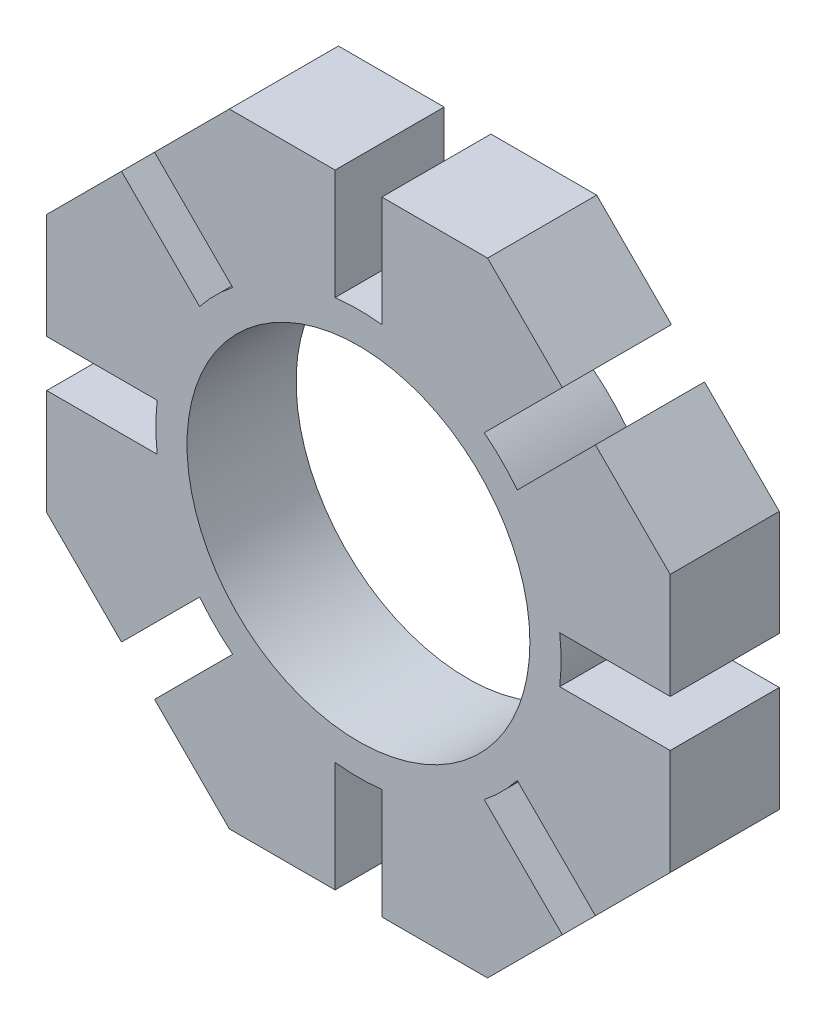
from build123d import *

# Parameters (mm, degrees)
SKETCH1_R               = 11
BOSS_EXTRUDE1_DEPTH     = 3.5
CUT_EXTRUDE3_REACH      = 46.858
CUT_EXTRUDE3_END_RADIUS = 13
SKETCH2_W               = 3
SKETCH2_H               = 8
CIRPATTERN1_COUNT       = 8


with BuildPart() as part:
    # Sketch1 → Boss-Extrude1 (new, symmetric)
    with BuildSketch(Plane.XY):
        Polygon((8.284271247, 20), (-8.284271247, 20), (-20, 8.284271247), (-20, -8.284271247), (-8.284271247, -20), (8.284271247, -20), (20, -8.284271247), (20, 8.284271247), align=None)
        Circle(SKETCH1_R, mode=Mode.SUBTRACT)
    extrude(amount=BOSS_EXTRUDE1_DEPTH, both=True)

    # Cut-Extrude3: up to this cylinder (the profile starts outside it)
    cut_extrude3_end = Plane(origin=(0, 0, 0), z_dir=(0, 0, -1)) * Cylinder(CUT_EXTRUDE3_END_RADIUS, 120.716, mode=Mode.PRIVATE)
    # Sketch2 → Cut-Extrude3 (cut, up to the surface)
    with BuildSketch(Plane(origin=(0, -20, 0), x_dir=(-1, 0, 0), z_dir=(0, -1, 0)), mode=Mode.PRIVATE) as cut_extrude3_sk1:
        Rectangle(SKETCH2_W, SKETCH2_H)
    cut_extrude3_tool1 = extrude(cut_extrude3_sk1.sketch, amount=-CUT_EXTRUDE3_REACH, mode=Mode.PRIVATE) - cut_extrude3_end
    cut_extrude3 = cut_extrude3_tool1.solids().sort_by_distance((0, -20, 0))[0]
    add(cut_extrude3, mode=Mode.SUBTRACT)

    # CirPattern1: Cut-Extrude3 ×8 about axis
    cirpattern1_axis = Axis((0, 0, 0), (0, 0, 1))
    for i in range(1, CIRPATTERN1_COUNT):
        add(cut_extrude3.rotate(cirpattern1_axis, i * 360 / CIRPATTERN1_COUNT), mode=Mode.SUBTRACT)


solid = part.part
